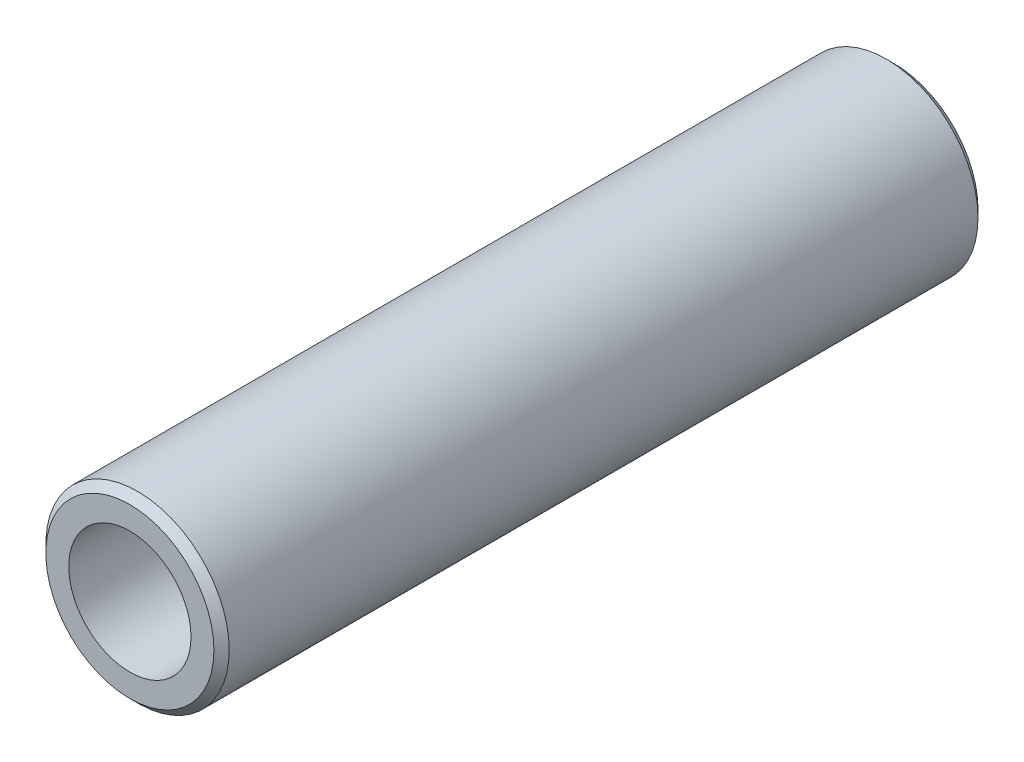
from build123d import *

# Parameters (mm, degrees)
SKETCH1_R           = 3
SKETCH1_R_2         = 2
BOSS_EXTRUDE1_DEPTH = 12.5
CHAMFER1_SIZE       = 0.25


with BuildPart() as part:
    # Sketch1 → Boss-Extrude1 (new body, symmetric)
    with BuildSketch(Plane.XY):
        Circle(SKETCH1_R)
        Circle(SKETCH1_R_2, mode=Mode.SUBTRACT)
    extrude(amount=BOSS_EXTRUDE1_DEPTH, both=True)

    # Chamfer1
    chamfer1_edges = [part.edges().sort_by_distance(p)[0] for p in [
        (-3, 0, -12.5),
        (-3, 0, 12.5),
    ]]
    chamfer(chamfer1_edges, length=CHAMFER1_SIZE)


solid = part.part
